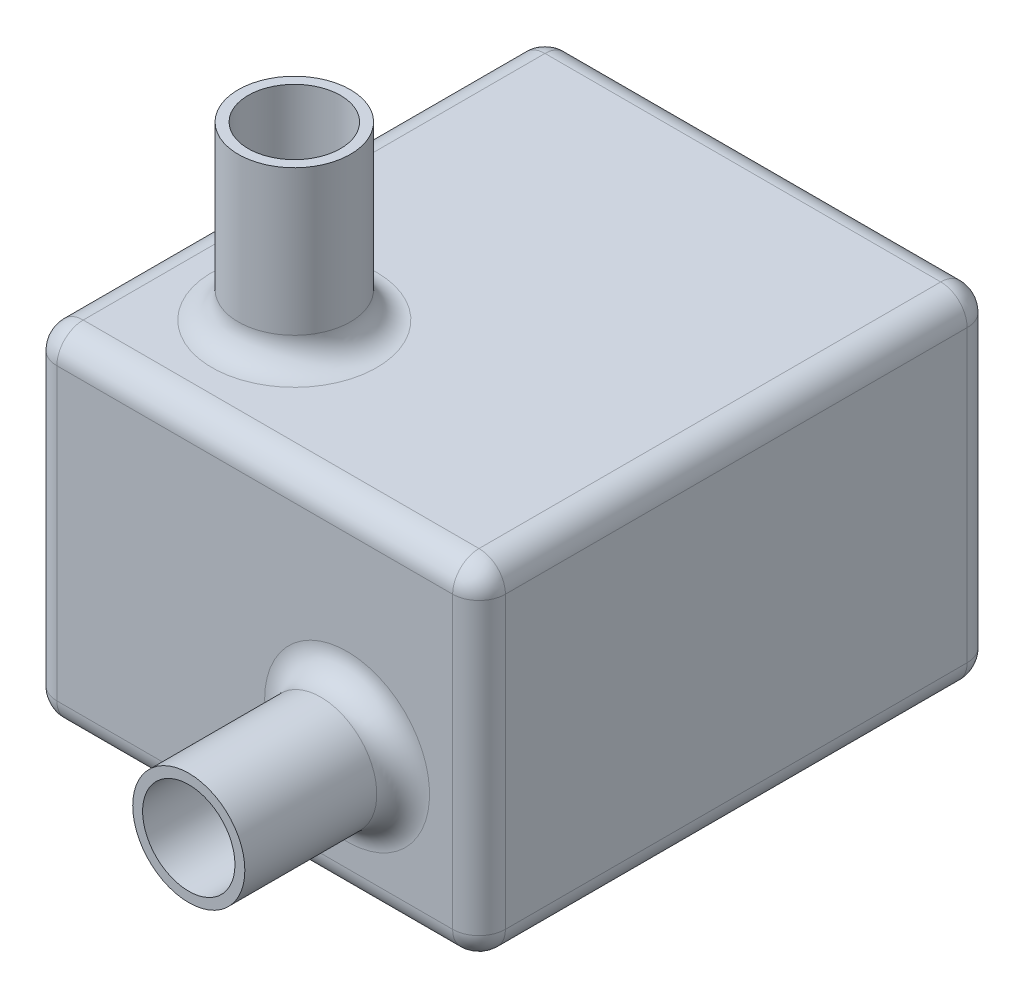
from build123d import *

# Parameters (mm, degrees)
SKETCH1_W           = 34
SKETCH1_H           = 39
BOSS_EXTRUDE1_DEPTH = 26
SKETCH2_R           = 4.25
SKETCH2_R_2         = 3.5
BOSS_EXTRUDE2_DEPTH = 13
SKETCH3_R           = 4.25
SKETCH3_R_2         = 3.5
BOSS_EXTRUDE4_DEPTH = 12
FILLET1_R           = 2
FILLET3_R           = 2
SKETCH5_R           = 2.5
BOSS_EXTRUDE5_DEPTH = 2


with BuildPart() as part:
    # Sketch1 → Boss-Extrude1 (new body)
    with BuildSketch(Plane(origin=(0, 0, 0), x_dir=(1, 0, 0), z_dir=(0, 1, 0))):
        Rectangle(SKETCH1_W, SKETCH1_H)
    extrude(amount=BOSS_EXTRUDE1_DEPTH)

    # Sketch2 → Boss-Extrude2 (add)
    with BuildSketch(Plane(origin=(0, 26, 0), x_dir=(1, 0, 0), z_dir=(0, 1, 0))):
        with Locations(Location((-7, -9.5, 0), (0, 0, 90))):
            Circle(SKETCH2_R)
        with Locations(Location((-7, -9.5, 0), (0, 0, 90))):
            Circle(SKETCH2_R_2, mode=Mode.SUBTRACT)
    extrude(amount=BOSS_EXTRUDE2_DEPTH)

    # Sketch3 → Boss-Extrude4 (add)
    with BuildSketch(Plane.XY.offset(19.5)):
        with Locations(Location((7, 10, 0), (0, 0, 180))):
            Circle(SKETCH3_R)
        with Locations((7, 10)):
            Circle(SKETCH3_R_2, mode=Mode.SUBTRACT)
    extrude(amount=BOSS_EXTRUDE4_DEPTH)

    # Fillet1
    fillet1_edges = [part.edges().sort_by_distance(p)[0] for p in [
        (-17, 26, 0),
        (0, 26, 19.5),
        (17, 26, 0),
        (0, 0, 19.5),
        (-17, 0, 0),
        (0, 0, -19.5),
        (17, 0, 0),
        (17, 13, 19.5),
        (-17, 13, 19.5),
        (-17, 13, -19.5),
        (17, 13, -19.5),
        (0, 26, -19.5),
    ]]
    fillet(fillet1_edges, radius=FILLET1_R)

    # Fillet3
    fillet3_edges = [part.edges().sort_by_distance(p)[0] for p in [
        (-7, 26, 13.75),
        (11.25, 10, 19.5),
    ]]
    fillet(fillet3_edges, radius=FILLET3_R)

    # Sketch5 → Boss-Extrude5 (add)
    with BuildSketch(Plane.XZ):
        Polygon((-15, -6), (-15, 0), (-15, 6), (-27, 6), (-27, -6), align=None)
        with Locations((-22.5, 0)):
            Circle(SKETCH5_R, mode=Mode.SUBTRACT)
        Polygon((15, 6), (15, 0), (15, -6), (27, -6), (27, 6), align=None)
        with BuildLine():
            ThreePointArc((25, 0), (22.5, -2.5), (20, 0))
            ThreePointArc((20, 0), (22.5, 2.5), (25, 0))
        make_face(mode=Mode.SUBTRACT)
    extrude(amount=BOSS_EXTRUDE5_DEPTH)


with BuildPart() as boss_extrude5_kept_piece:
    # of the separate pieces the step leaves, the one the design keeps (boss_extrude5_pieces_kept)
    add(part.part.solids().sort_by_distance((0.75, 10, 19.5))[0])


solid = boss_extrude5_kept_piece.part
